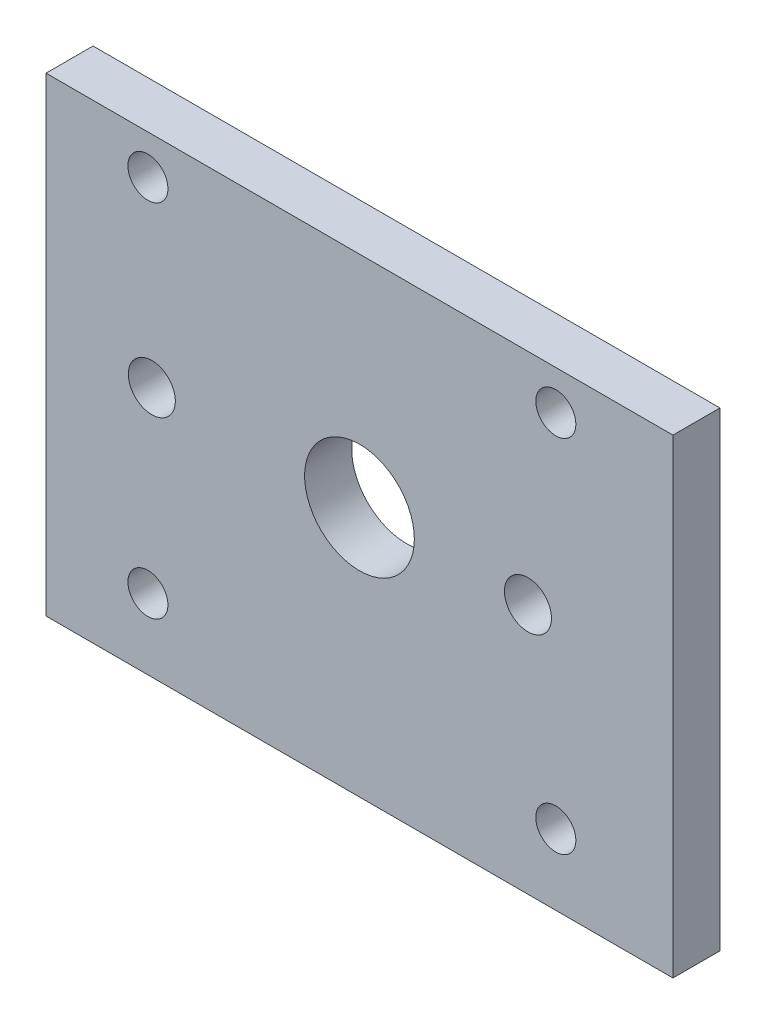
from build123d import *

# Parameters (mm, degrees)
SKETCH_1_W          = 80
SKETCH_1_H          = 60
SKETCH_1_R          = 7
EXTRUDE_1_DEPTH     = 6
SKETCH_2_R          = 3
SKETCH_2_R_2        = 2.555087711
CUT_EXTRUDE_1_DEPTH = 10


with BuildPart() as part:
    # 草图1 → 凸台-拉伸1 (new body)
    with BuildSketch(Plane.XY):
        with Locations((0, 5)):
            Rectangle(SKETCH_1_W, SKETCH_1_H)
        with Locations((0, 7)):
            Circle(SKETCH_1_R, mode=Mode.SUBTRACT)
    extrude(amount=EXTRUDE_1_DEPTH)

    # 草图2 → 切除-拉伸1 (cut)
    with BuildSketch(Plane(origin=(0, 0, 0), x_dir=(-1, 0, 0), z_dir=(0, 0, -1))):
        with Locations((-21.5, 7)):
            Circle(SKETCH_2_R)
        with Locations((26.5, 7)):
            Circle(SKETCH_2_R)
        with Locations((27, 30)):
            Circle(SKETCH_2_R_2)
        with Locations((27, -16)):
            Circle(SKETCH_2_R_2)
        with Locations((-25.052626778, -16)):
            Circle(SKETCH_2_R_2)
        with Locations((-25.052626778, 30)):
            Circle(SKETCH_2_R_2)
    extrude(amount=-CUT_EXTRUDE_1_DEPTH, mode=Mode.SUBTRACT)


solid = part.part
